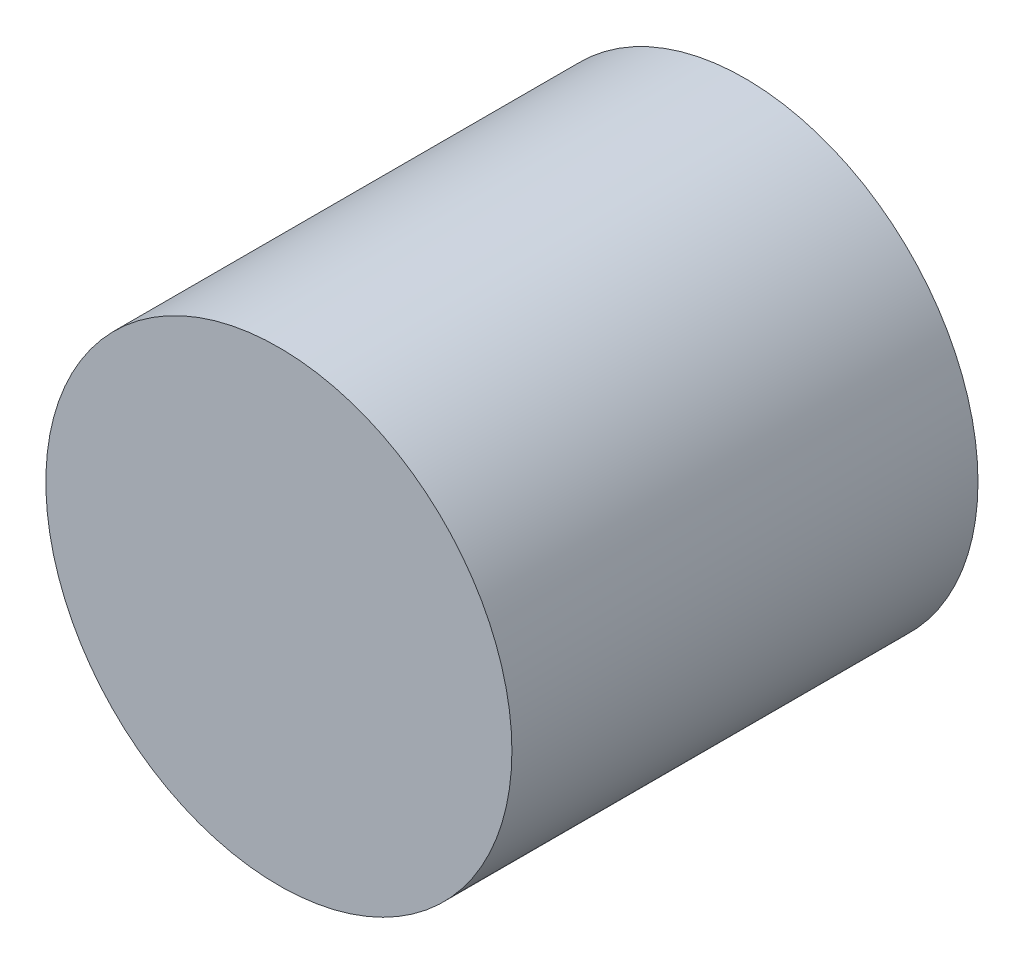
from build123d import *

# Parameters (mm, degrees)
SKETCH_1_R      = 10
EXTRUDE_1_DEPTH = 20


with BuildPart() as part:
    # Эскиз1 → Бобышка-Вытянуть1 (new body)
    with BuildSketch(Plane.XY):
        Circle(SKETCH_1_R)
    extrude(amount=EXTRUDE_1_DEPTH)


solid = part.part
